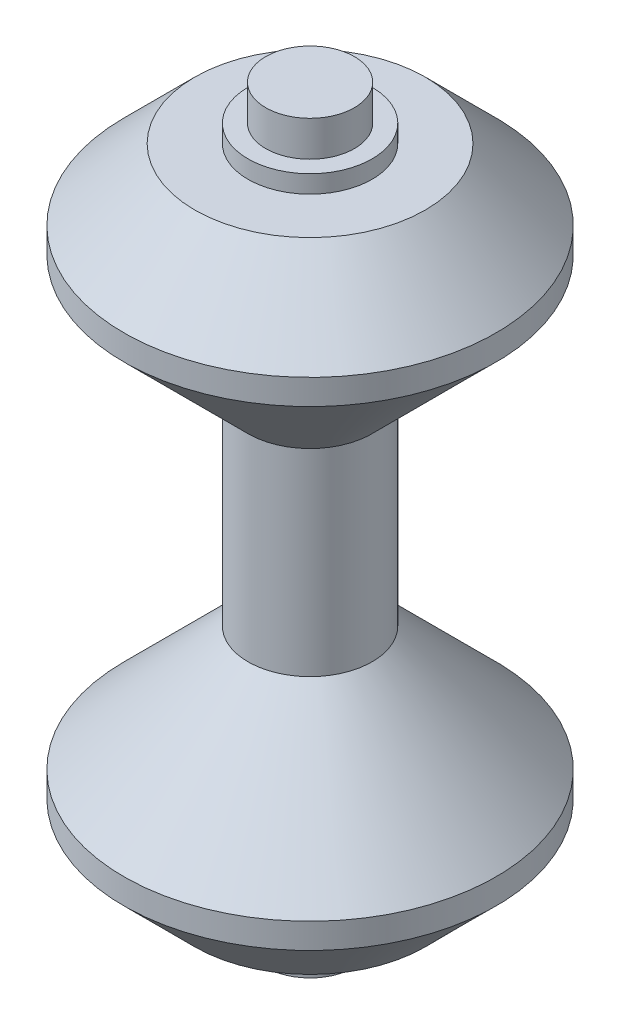
from build123d import *


with BuildPart() as part:
    # Sketch1 → Revolve1 (revolve)
    with BuildSketch(Plane.XY):
        Polygon((0, 21), (0, 0), (3.5, 0), (3.5, 5.571782079), (10.5, 12.571782079), (10.5, 14), (6.5, 18), (3.5, 18), (3.5, 19), (2.5, 19), (2.5, 21), align=None)
    revolve1 = revolve(axis=Axis((0, 21, 0), (0, -1, 0)))

    # Mirror1: Revolve1 across plane
    add(revolve1.mirror(Plane.ZX))


solid = part.part
